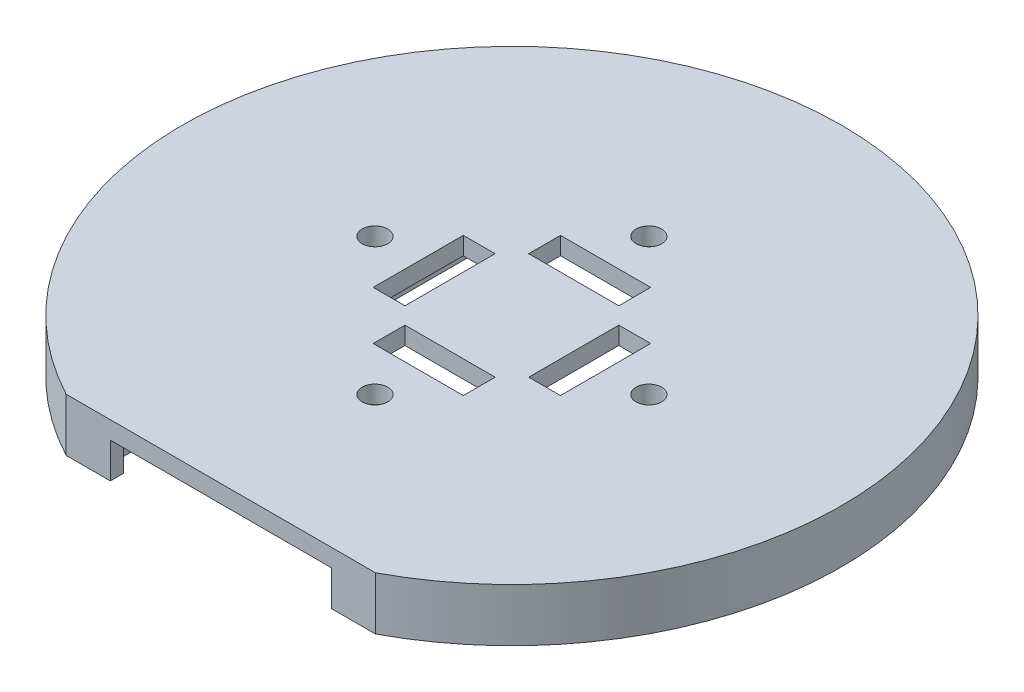
from build123d import *

# Parameters (mm, degrees)
BOSS_EXTRUDE1_DEPTH = 6
SKETCH2_W           = 28.3
SKETCH2_H           = 64.3
CUT_EXTRUDE1_DEPTH  = 4
SKETCH3_R           = 1.45
SKETCH3_W           = 10.2
SKETCH3_H           = 3.6
CUT_EXTRUDE2_DEPTH  = 7
CIRPATTERN1_COUNT   = 4
CUT_EXTRUDE3_REACH  = 72.24
SKETCH4_W           = 25
SKETCH4_H           = 4


with BuildPart() as part:
    # Sketch1 → Boss-Extrude1 (new body)
    with BuildSketch(Plane(origin=(0, 0, 0), x_dir=(1, 0, 0), z_dir=(0, 1, 0))):
        with BuildLine():
            Line((-17.5, -32.939945355), (17.5, -32.939945355))
            ThreePointArc((17.5, -32.939945355), (0, 37.3), (-17.5, -32.939945355))
        make_face()
    extrude(amount=BOSS_EXTRUDE1_DEPTH)

    # Sketch2 → Cut-Extrude1 (cut)
    with BuildSketch(Plane.XZ):
        with Locations((0, -0.710054645)):
            Rectangle(SKETCH2_W, SKETCH2_H)
    extrude(amount=-CUT_EXTRUDE1_DEPTH, mode=Mode.SUBTRACT)

    # Sketch3 → Cut-Extrude2 (cut, through all)
    with BuildSketch(Plane(origin=(0, 6, 0), x_dir=(1, 0, 0), z_dir=(0, 1, 0))):
        with Locations((0, 15.5)):
            Circle(SKETCH3_R)
        with Locations((0, 8.8)):
            Rectangle(SKETCH3_W, SKETCH3_H)
    cut_extrude2 = extrude(amount=-CUT_EXTRUDE2_DEPTH, mode=Mode.SUBTRACT)

    # CirPattern1: Cut-Extrude2 ×4 about axis
    cirpattern1_axis = Axis((0, 0, 0), (0, 1, 0))
    for i in range(1, CIRPATTERN1_COUNT):
        add(cut_extrude2.rotate(cirpattern1_axis, i * 360 / CIRPATTERN1_COUNT), mode=Mode.SUBTRACT)

    # Sketch4 → Cut-Extrude3 (cut, up to next)
    with BuildSketch(Plane.XY.offset(32.939945355), mode=Mode.PRIVATE) as cut_extrude3_sk1:
        with Locations((0, 2)):
            Rectangle(SKETCH4_W, SKETCH4_H)
    cut_extrude3_tool1 = extrude(cut_extrude3_sk1.sketch, amount=-CUT_EXTRUDE3_REACH, mode=Mode.PRIVATE) & part.part
    add(cut_extrude3_tool1.solids().sort_by_distance((0, 2, 32.939945))[0], mode=Mode.SUBTRACT)


solid = part.part
